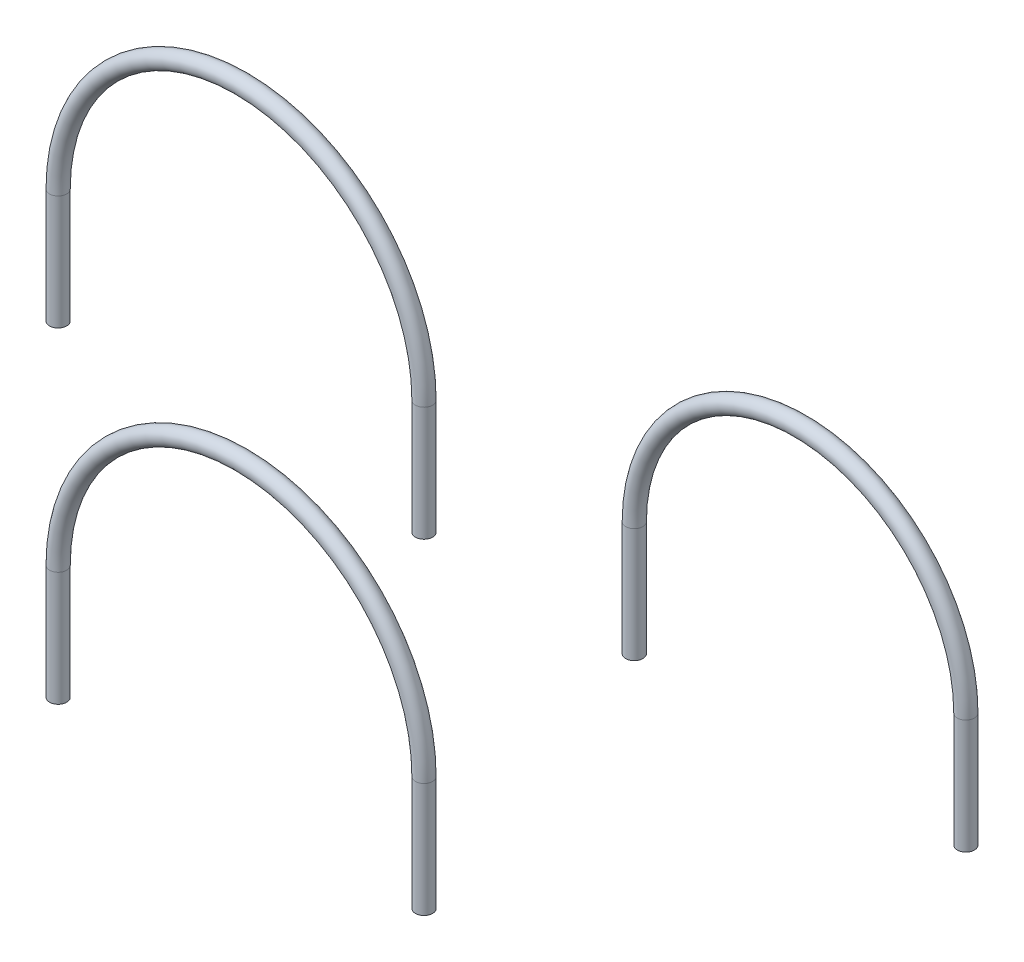
from build123d import *

# Parameters (mm, degrees)
SWEEP_THIN1_PROFILE_R   = 30
SWEEP_THIN1_PROFILE_R_2 = 27
SWEEP_THIN2_PROFILE_R   = 30
SWEEP_THIN2_PROFILE_R_2 = 27
LPATTERN1_COUNT         = 2
LPATTERN1_PITCH         = 1140


with BuildPart() as part:
    # Sweep-Thin1: sweep along a path in Sketch1
    with BuildLine(Plane.XY) as sweep_thin1_path:
        Line((-576.668413478, -400), (-576.668413478, 0))
        ThreePointArc((-576.668413478, 0), (63.331586522, 640), (703.331586522, 0))
        Line((703.331586522, 0), (703.331586522, -400))
    # Sweep-Thin1 profile (on start of the path) → Sweep-Thin1 (sweep)
    with BuildSketch(Plane(origin=(-576.668413478, -400, 0), x_dir=(1, 0, 0), z_dir=(0, 1, 0))):
        Circle(SWEEP_THIN1_PROFILE_R)
        Circle(SWEEP_THIN1_PROFILE_R_2, mode=Mode.SUBTRACT)
    sweep(path=sweep_thin1_path.line)


with BuildPart() as body_2:
    # Sweep-Thin2: sweep along a path in Sketch22
    with BuildLine(Plane.XY) as sweep_thin2_path:
        Line((1438.966961175, -400), (1438.966961175, 0))
        ThreePointArc((1438.966961175, 0), (2018.966961175, 580), (2598.966961175, 0))
        Line((2598.966961175, 0), (2598.966961175, -400))
    # Sweep-Thin2 profile (on start of the path) → Sweep-Thin2 (sweep)
    with BuildSketch(Plane(origin=(1438.966961175, -400, 0), x_dir=(0, 0, 1), z_dir=(0, 1, 0))):
        Circle(SWEEP_THIN2_PROFILE_R)
        Circle(SWEEP_THIN2_PROFILE_R_2, mode=Mode.SUBTRACT)
    sweep(path=sweep_thin2_path.line)


with BuildPart() as lpattern1_1:
    # LPattern1: pattern copy
    add(part.part.moved(Location(Vector(0, -1, 0) * (1 * LPATTERN1_PITCH))))


solid = Compound([part.part, body_2.part, lpattern1_1.part])
